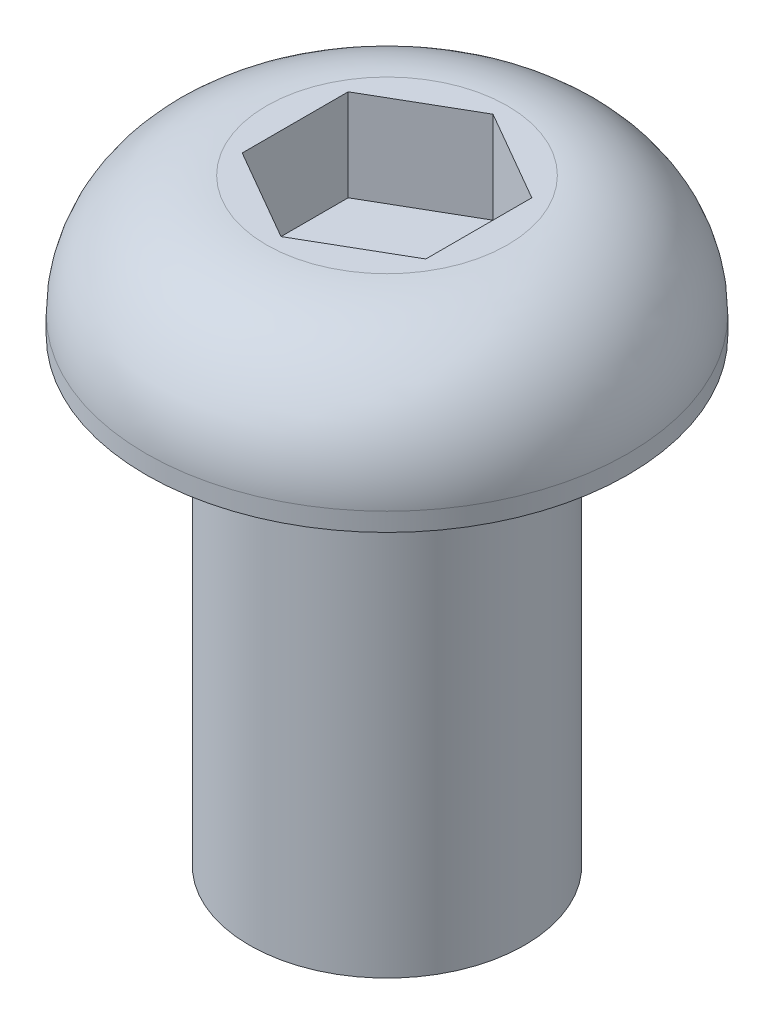
from build123d import *

# Parameters (mm, degrees)
CORTE_EXTRUS_O1_DEPTH = 4


with BuildPart() as part:
    # Esboço1 → Revolução1 (revolve)
    with BuildSketch(Plane.XY):
        with BuildLine():
            Line((0, 0), (6, 0))
            Line((6, 0), (6, 20))
            Line((6, 20), (10.5, 20))
            Line((10.5, 20), (10.5, 20.8))
            ThreePointArc((10.5, 20.8), (8.962310601, 24.512310601), (5.25, 26.05))
            Line((5.25, 26.05), (0, 26.05))
            Line((0, 26.05), (0, 0))
        make_face()
    revolve(axis=Axis((0, 26.05, 0), (0, -1, 0)))

    # Esboço2 → Corte-extrusão1 (cut)
    with BuildSketch(Plane(origin=(0, 26.05, 0), x_dir=(1, 0, 0), z_dir=(0, 1, 0))):
        Polygon((-4, -2.309401077), (0, -4.618802154), (4, -2.309401077), (4, 2.309401077), (0, 4.618802154), (-4, 2.309401077), align=None)
    extrude(amount=-CORTE_EXTRUS_O1_DEPTH, mode=Mode.SUBTRACT)


solid = part.part
